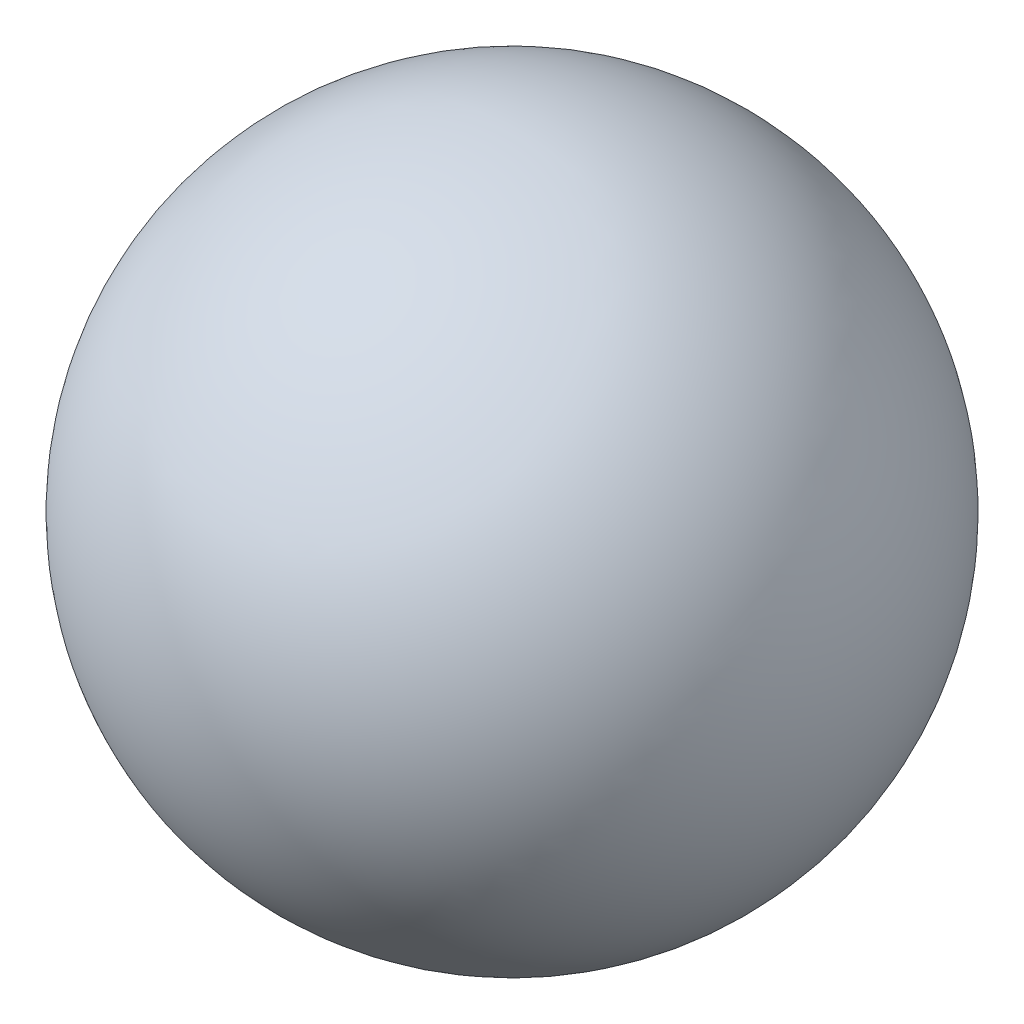
from build123d import *

# Parameters (mm, degrees)
SKETCH2_R          = 10.5
CUT_EXTRUDE1_DEPTH = 151


with BuildPart() as part:
    # Sketch1 → Revolve1 (revolve)
    with BuildSketch(Plane(origin=(0, 0, 0), x_dir=(1, 0, 0), z_dir=(0, 1, 0))):
        with BuildLine():
            Line((0, -39), (0, 39))
            ThreePointArc((0, 39), (-39, 0), (0, -39))
        make_face()
    revolve(axis=Axis((0, 0, 39), (0, 0, -1)))

    # Sketch2 → Cut-Extrude1 (cut)
    with BuildSketch(Plane.XY):
        Circle(SKETCH2_R)
    extrude(amount=-CUT_EXTRUDE1_DEPTH, mode=Mode.SUBTRACT)


solid = part.part
